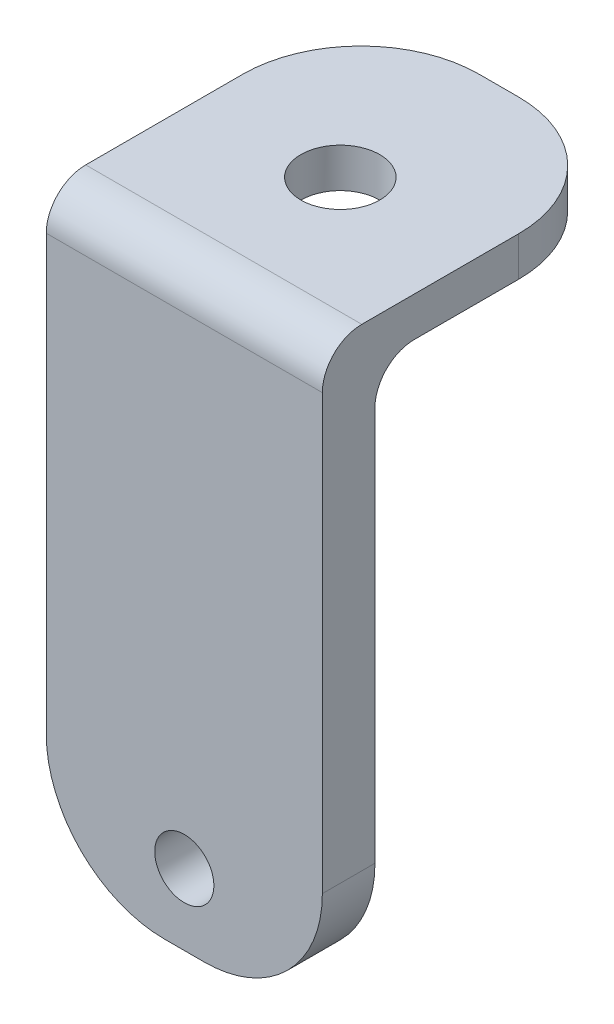
from build123d import *

# Parameters (mm, degrees)
BOSS_EXTRUDE1_DEPTH      = 35
BOSS_EXTRUDE1_DEPTH_BACK = 35
SKETCH2_R                = 10
CUT_EXTRUDE1_DEPTH       = 35
SKETCH3_R                = 7.5
CUT_EXTRUDE2_DEPTH       = 80.78895104
FILLET1_R                = 30
FILLET2_R                = 10


with BuildPart() as part:
    # Sketch1 → Boss-Extrude1 (new body, two sides)
    with BuildSketch(Plane(origin=(0, 0, 0), x_dir=(0, 0, -1), z_dir=(1, 0, 0))) as boss_extrude1_sk:
        Polygon((-42.056921018, 166.399972685), (-42.056921018, 60.21769331), (-28.717037647, 60.21769331), (-28.717037647, 200.21769331), (37.732030022, 200.21769331), (37.732030022, 210.21769331), (-42.056921018, 210.21769331), align=None)
    extrude(amount=BOSS_EXTRUDE1_DEPTH)
    extrude(boss_extrude1_sk.sketch, amount=-BOSS_EXTRUDE1_DEPTH_BACK)

    # Sketch2 → Cut-Extrude1 (cut)
    with BuildSketch(Plane(origin=(0, 210.21769331, 0), x_dir=(1, 0, 0), z_dir=(0, 1, 0))):
        with Locations((0, -2.5)):
            Circle(SKETCH2_R)
    extrude(amount=-CUT_EXTRUDE1_DEPTH, mode=Mode.SUBTRACT)

    # Sketch3 → Cut-Extrude2 (cut, through all)
    with BuildSketch(Plane.XY.offset(42.056921018)):
        with Locations((0, 78.21769331)):
            Circle(SKETCH3_R)
    extrude(amount=-CUT_EXTRUDE2_DEPTH, mode=Mode.SUBTRACT)

    # Fillet1
    fillet1_edges = [part.edges().sort_by_distance(p)[0] for p in [
        (-35, 60.21769331, 35.386979332),
        (35, 60.21769331, 35.386979332),
        (35, 205.21769331, -37.732030022),
        (-35, 205.21769331, -37.732030022),
    ]]
    fillet(fillet1_edges, radius=FILLET1_R)

    # Fillet2
    fillet2_edges = [part.edges().sort_by_distance(p)[0] for p in [
        (0, 210.21769331, 42.056921018),
        (0, 200.21769331, 28.717037647),
    ]]
    fillet(fillet2_edges, radius=FILLET2_R)


solid = part.part
